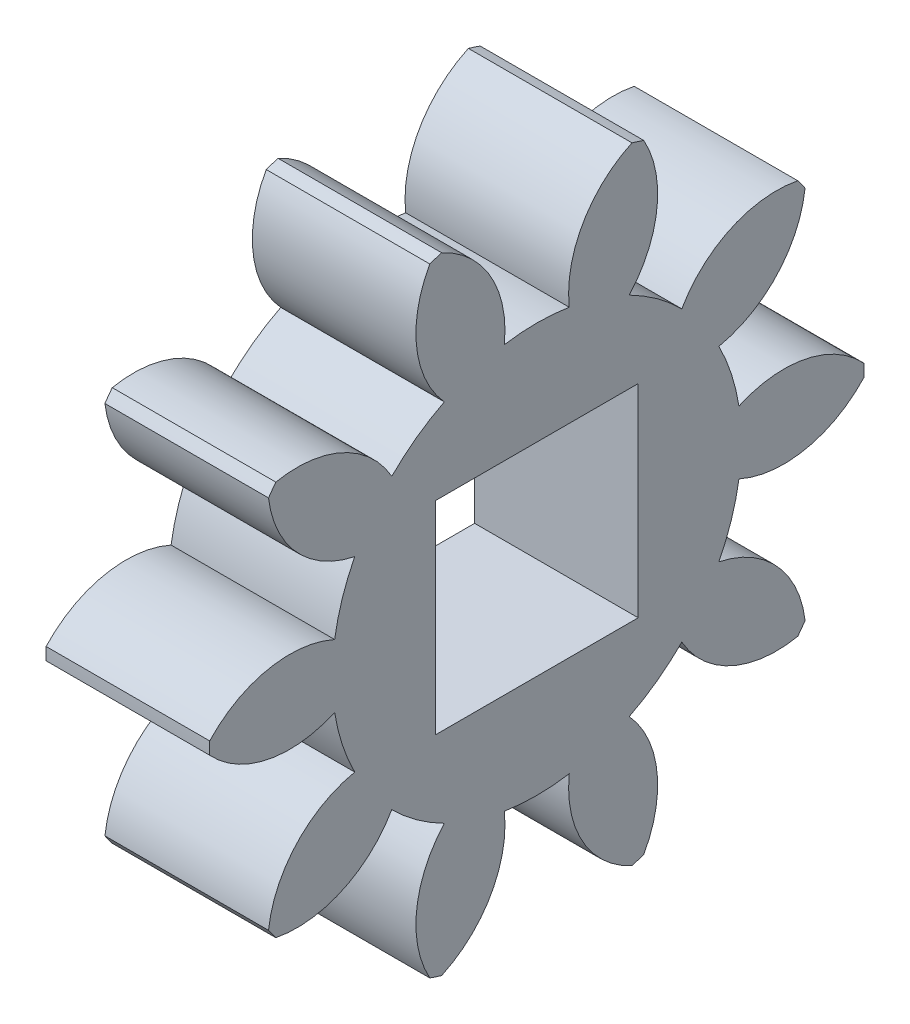
from build123d import *

# Parameters (mm, degrees)
BASPROSKE_W             = 3.175
BASPROSKE_H             = 6.35
TOOTHCUT_DEPTH          = 10.525
TEETHCUTS_COUNT         = 10
TEETHCUTS_ANGLE         = 324
BORSKE_R                = 0.99949
BORE_DEPTH              = 50.8000508
SKETCH1_W               = 3.937
SKETCH1_H               = 3.937
CUT_EXTRUDE1_DEPTH      = 10.344170464
CUT_EXTRUDE1_DEPTH_BACK = 10.344170464


with BuildPart() as part:
    # BasProSke → Base-Revolve (revolve)
    with BuildSketch(Plane(origin=(0, 0, 0), x_dir=(1, 0, 0), z_dir=(0, 1, 0)), mode=Mode.PRIVATE) as base_revolve_sk:
        with Locations((1.5875, 3.175)):
            Rectangle(BASPROSKE_W, BASPROSKE_H)
    revolve(base_revolve_sk.sketch.rotate(Axis((-10, 0, 0), (1, 0, 0)), 180), axis=Axis((-10, 0, 0), (1, 0, 0)))

    # TooCutSke → ToothCut (cut, through all)
    with BuildSketch(Plane(origin=(0, 0, 0), x_dir=(0, 0, -1), z_dir=(1, 0, 0))):
        with BuildLine():
            ThreePointArc((0.630210727, 3.920537785), (0, 3.970866667), (-0.630210727, 3.920537785))
            ThreePointArc((-0.630210727, 3.920537785), (-0.900510691, 5.2110639), (-1.88228345, 6.091201374))
            ThreePointArc((-1.88228345, 6.091201374), (0, 6.3754), (1.88228345, 6.091201374))
            ThreePointArc((1.88228345, 6.091201374), (0.900510691, 5.2110639), (0.630210727, 3.920537785))
        make_face()
    toothcut = extrude(amount=TOOTHCUT_DEPTH, mode=Mode.SUBTRACT)

    # TeethCuts: ToothCut ×10 about axis
    teethcuts_axis = Axis((-10, 0, 0), (1, 0, 0))
    for i in range(1, TEETHCUTS_COUNT):
        add(toothcut.rotate(teethcuts_axis, i * TEETHCUTS_ANGLE / (TEETHCUTS_COUNT - 1)), mode=Mode.SUBTRACT)

    # BorSke → Bore (cut, symmetric)
    with BuildSketch(Plane(origin=(0, 0, 0), x_dir=(0, 0, -1), z_dir=(1, 0, 0))):
        with Locations(Location((0, 0, 0), (0, 0, 180))):
            Circle(BORSKE_R)
    extrude(amount=BORE_DEPTH, both=True, mode=Mode.SUBTRACT)

    # Sketch1 → Cut-Extrude1 (cut, two sides)
    with BuildSketch(Plane(origin=(3.175, 0, 0), x_dir=(0, 0, -1), z_dir=(1, 0, 0))) as cut_extrude1_sk:
        Rectangle(SKETCH1_W, SKETCH1_H)
    extrude(amount=CUT_EXTRUDE1_DEPTH, mode=Mode.SUBTRACT)
    extrude(cut_extrude1_sk.sketch, amount=-CUT_EXTRUDE1_DEPTH_BACK, mode=Mode.SUBTRACT)


solid = part.part
